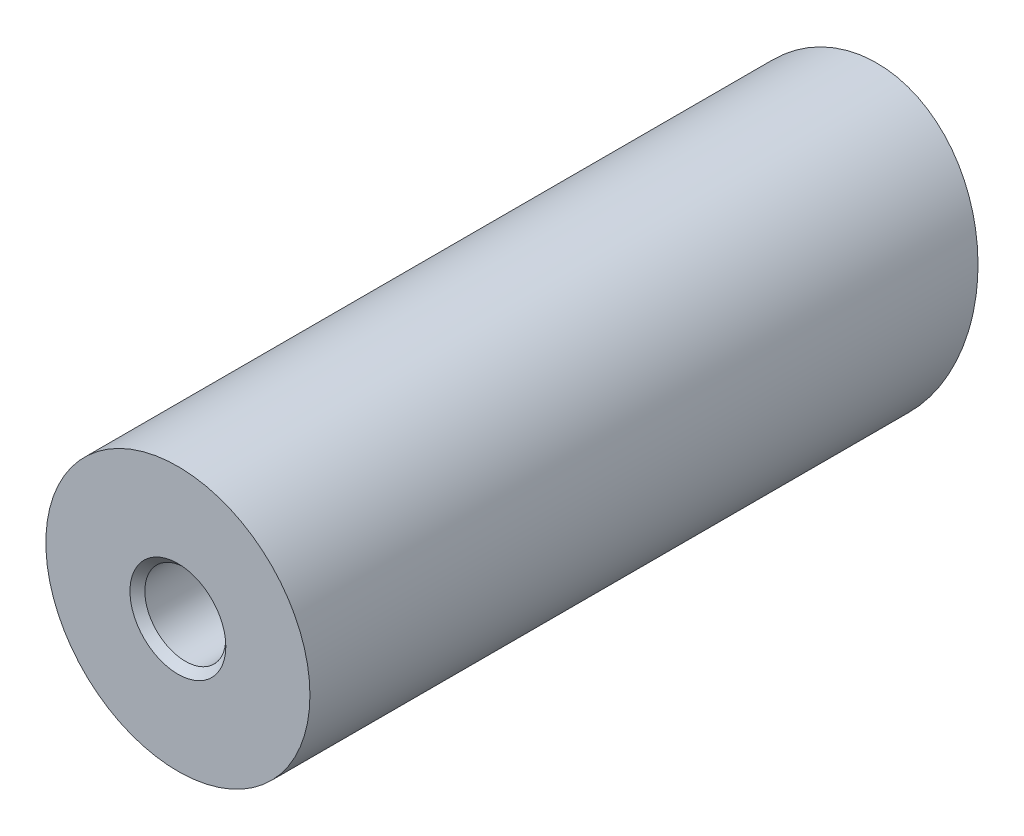
from build123d import *

# Parameters (mm, degrees)
SKIZZE1_W                       = 58.664904562
SKIZZE1_H                       = 11.08559322
SCHNITT_LINEAR_AUSTRAGEN1_DEPTH = 13
M8_GEWINDEBOHRUNG1_D            = 6.8
M8_GEWINDEBOHRUNG1_DEPTH        = 22.25
M8_GEWINDEBOHRUNG1_CSINK_D      = 8.05
M8_GEWINDEBOHRUNG1_CSINK_ANGLE  = 90
M8_GEWINDEBOHRUNG1_TIP          = 2.042926105
M8_GEWINDEBOHRUNG2_D            = 6.8
M8_GEWINDEBOHRUNG2_DEPTH        = 22.25
M8_GEWINDEBOHRUNG2_CSINK_D      = 8.05
M8_GEWINDEBOHRUNG2_CSINK_ANGLE  = 90
M8_GEWINDEBOHRUNG2_TIP          = 2.042926105


with BuildPart() as part:
    # Skizze1 → Rotation1 (revolve)
    with BuildSketch(Plane(origin=(0, 0, 0), x_dir=(0, 0, -1), z_dir=(1, 0, 0)), mode=Mode.PRIVATE) as rotation1_sk:
        with Locations((29.332452281, 5.54279661)):
            Rectangle(SKIZZE1_W, SKIZZE1_H)
    revolve(rotation1_sk.sketch.rotate(Axis((0, 0, 0), (0, 0, -1)), 90), axis=Axis((0, 0, 0), (0, 0, -1)))  # turned: the seam where the file's is

    # Skizze2 → Schnitt-Linear austragen1 (cut, symmetric)
    with BuildSketch(Plane(origin=(0, 0, 0), x_dir=(0, 0, -1), z_dir=(1, 0, 0))):
        Polygon((58.664904562, 11.08559322), (52.72415306, -11.08559322), (58.664904562, -11.08559322), align=None)
    extrude(amount=SCHNITT_LINEAR_AUSTRAGEN1_DEPTH, both=True, mode=Mode.SUBTRACT)

    # M8 Gewindebohrung1
    with Locations(Plane.XY):
        with Locations((0, 0)):
            CounterSinkHole(M8_GEWINDEBOHRUNG1_D / 2, M8_GEWINDEBOHRUNG1_CSINK_D / 2, depth=M8_GEWINDEBOHRUNG1_DEPTH, counter_sink_angle=M8_GEWINDEBOHRUNG1_CSINK_ANGLE)
            with Locations((0, 0, -(M8_GEWINDEBOHRUNG1_DEPTH + M8_GEWINDEBOHRUNG1_TIP / 2))):  # 118° drill point
                Cone(0, M8_GEWINDEBOHRUNG1_D / 2, M8_GEWINDEBOHRUNG1_TIP, mode=Mode.SUBTRACT)

    # M8 Gewindebohrung2
    with Locations(Plane(origin=(0, 0, -58.664904562), x_dir=(1, 0, 0), z_dir=(0, 0, -1))):
        with Locations((0, 0)):
            CounterSinkHole(M8_GEWINDEBOHRUNG2_D / 2, M8_GEWINDEBOHRUNG2_CSINK_D / 2, depth=M8_GEWINDEBOHRUNG2_DEPTH, counter_sink_angle=M8_GEWINDEBOHRUNG2_CSINK_ANGLE)
            with Locations((0, 0, -(M8_GEWINDEBOHRUNG2_DEPTH + M8_GEWINDEBOHRUNG2_TIP / 2))):  # 118° drill point
                Cone(0, M8_GEWINDEBOHRUNG2_D / 2, M8_GEWINDEBOHRUNG2_TIP, mode=Mode.SUBTRACT)


solid = part.part
